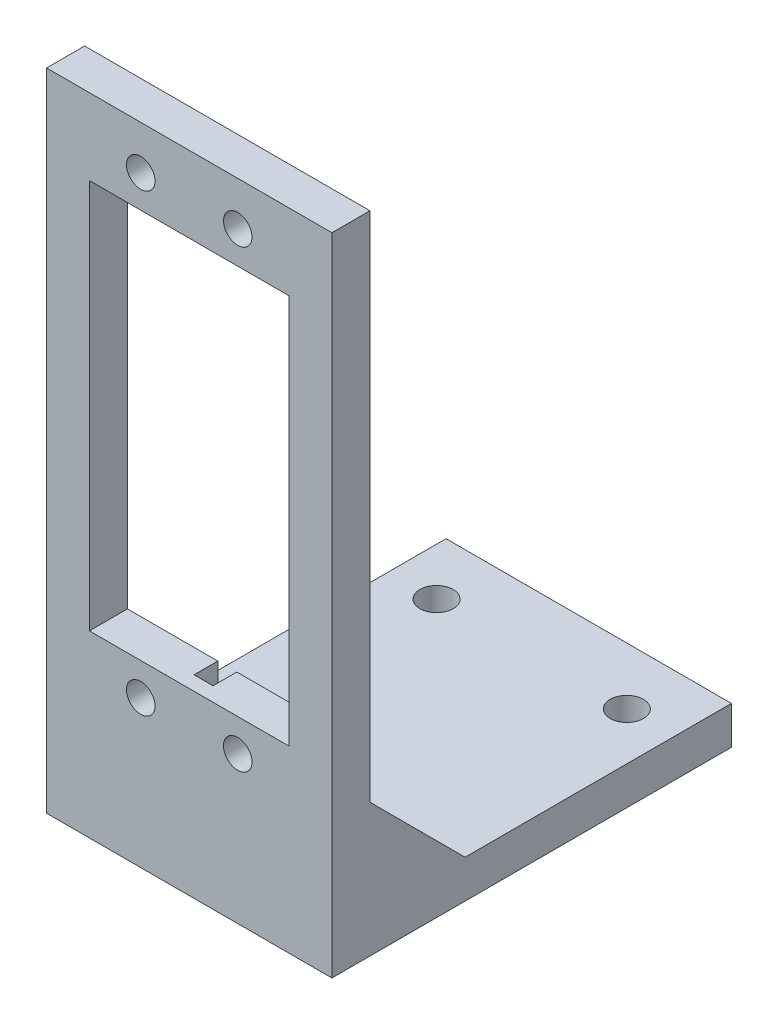
from build123d import *

# Parameters (mm, degrees)
SKETCH_1_W          = 30
SKETCH_1_H          = 63.8558669
SKETCH_1_R          = 1.5
SKETCH_1_W_2        = 21
SKETCH_1_H_2        = 41
EXTRUDE_1_DEPTH     = 4
SKETCH_2_W          = 2
SKETCH_2_H          = 3
CUT_EXTRUDE_1_DEPTH = 2.5
SKETCH_3_W          = 30
SKETCH_3_H          = 42
EXTRUDE_2_DEPTH     = 4
SKETCH_4_R          = 1.75
CUT_EXTRUDE_2_DEPTH = 5
EXTRUDE_3_DEPTH     = 3
EXTRUDE_4_DEPTH     = 3


with BuildPart() as part:
    # 草圖1 → 填料-伸長1 (new body)
    with BuildSketch(Plane.XY):
        with Locations((15, 31.92793345)):
            Rectangle(SKETCH_1_W, SKETCH_1_H)
        with Locations((9.9, 59.2558669)):
            Circle(SKETCH_1_R, mode=Mode.SUBTRACT)
        with Locations((20.1, 59.2558669)):
            Circle(SKETCH_1_R, mode=Mode.SUBTRACT)
        with Locations((20.1, 11.4558669)):
            Circle(SKETCH_1_R, mode=Mode.SUBTRACT)
        with Locations((9.9, 11.4558669)):
            Circle(SKETCH_1_R, mode=Mode.SUBTRACT)
        with Locations((15, 35.3558669)):
            Rectangle(SKETCH_1_W_2, SKETCH_1_H_2, mode=Mode.SUBTRACT)
    extrude(amount=EXTRUDE_1_DEPTH)

    # 草圖2 → 除料-伸長1 (cut)
    with BuildSketch(Plane(origin=(0, 0, 0), x_dir=(-1, 0, 0), z_dir=(0, 0, -1))):
        with Locations((-15, 57.3558669)):
            Rectangle(SKETCH_2_W, SKETCH_2_H)
        with Locations((-15, 13.3558669)):
            Rectangle(SKETCH_2_W, SKETCH_2_H)
    extrude(amount=-CUT_EXTRUDE_1_DEPTH, mode=Mode.SUBTRACT)

    # 草圖3 → 填料-伸長2 (add)
    with BuildSketch(Plane.XZ):
        with Locations((15, -17)):
            Rectangle(SKETCH_3_W, SKETCH_3_H)
    extrude(amount=EXTRUDE_2_DEPTH)

    # 草圖4 → 除料-伸長2 (cut, through all)
    with BuildSketch(Plane(origin=(0, 0, 0), x_dir=(1, 0, 0), z_dir=(0, 1, 0))):
        with Locations((5, 32)):
            Circle(SKETCH_4_R)
        with Locations((25, 32)):
            Circle(SKETCH_4_R)
    extrude(amount=-CUT_EXTRUDE_2_DEPTH, mode=Mode.SUBTRACT)

    # 草圖5 → 填料-伸長3 (add)
    with BuildSketch(Plane(origin=(30, 0, 0), x_dir=(0, 0, -1), z_dir=(1, 0, 0))):
        Polygon((0, 10), (10, 0), (0, 0), align=None)
    extrude(amount=-EXTRUDE_3_DEPTH)

    # 草圖6 → 填料-伸長4 (add)
    with BuildSketch(Plane.ZY):
        Polygon((0, 0), (0, 10), (-10, 0), align=None)
    extrude(amount=-EXTRUDE_4_DEPTH)


solid = part.part
